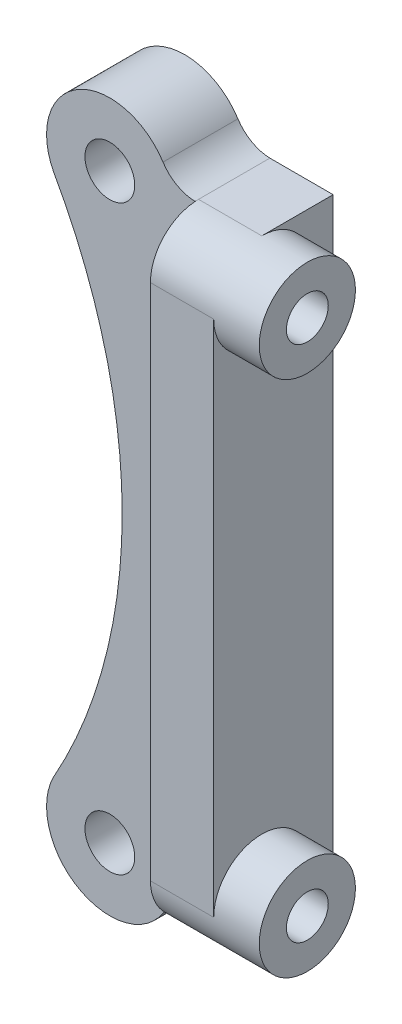
from build123d import *

# Parameters (mm, degrees)
EXTRUDE1_DEPTH     = 15.875
SKETCH2_R          = 12.065
EXTRUDE2_DEPTH     = 11.43
EXTRUDE4_DEPTH     = 18.796
SKETCH5_R          = 6.2484
CUT_EXTRUDE1_DEPTH = 19.796
SKETCH7_R          = 5.25018
CUT_EXTRUDE2_DEPTH = 25.4


with BuildPart() as part:
    # Sketch1 → Extrude1 (new body)
    with BuildSketch(Plane(origin=(0, 0, 0), x_dir=(0, 0, -1), z_dir=(1, 0, 0))):
        with BuildLine():
            Line((17.907, -77.0636), (17.907, 77.0636))
            Line((17.907, 77.0636), (0, 77.0636))
            ThreePointArc((0, 77.0636), (-8.531243315, 73.529843315), (-12.065, 64.9986))
            Line((-12.065, 64.9986), (-12.065, -64.9986))
            ThreePointArc((-12.065, -64.9986), (-8.531243315, -73.529843315), (0, -77.0636))
            Line((0, -77.0636), (17.907, -77.0636))
        make_face()
    extrude(amount=EXTRUDE1_DEPTH)

    # Sketch2 → Extrude2 (add)
    with BuildSketch(Plane(origin=(15.875, 0, 0), x_dir=(0, 0, -1), z_dir=(1, 0, 0))):
        with Locations(Location((0, 64.9986, 0), (0, 0, 180))):  # turned: the seam where the file's is
            Circle(SKETCH2_R)
    extrude2 = extrude(amount=EXTRUDE2_DEPTH)

    # Mirror of Extrude 2: Extrude2 across plane
    add(extrude2.mirror(Plane.ZX))

    # Sketch4 → Extrude4 (add)
    with BuildSketch(Plane(origin=(0, 0, -17.907), x_dir=(-1, 0, 0), z_dir=(0, 0, -1))):
        with BuildLine():
            ThreePointArc((8.015455062, 81.59619111), (4.56701856, 78.340842715), (0, 77.0636))
            Line((0, 77.0636), (0, -77.0636))
            ThreePointArc((0, -77.0636), (4.56701856, -78.340842715), (8.015455062, -81.59619111))
            ThreePointArc((8.015455062, -81.59619111), (29.290525196, -86.75258508), (35.488071258, -65.757170562))
            ThreePointArc((35.488071258, -65.757170562), (18.264230861, 0), (35.488071258, 65.757170562))
            ThreePointArc((35.488071258, 65.757170562), (29.290525196, 86.75258508), (8.015455062, 81.59619111))
        make_face()
    extrude(amount=-EXTRUDE4_DEPTH)

    # Sketch5 → Cut-Extrude1 (cut, through all)
    with BuildSketch(Plane.XY.offset(0.889)):
        with Locations((-21.3614, 72.9996)):
            Circle(SKETCH5_R)
    cut_extrude1 = extrude(amount=-CUT_EXTRUDE1_DEPTH, mode=Mode.SUBTRACT)

    # Sketch7 → Cut-Extrude2 (cut)
    with BuildSketch(Plane(origin=(27.305, 0, 0), x_dir=(0, 0, -1), z_dir=(1, 0, 0))):
        with Locations((0, 64.9986)):
            Circle(SKETCH7_R)
    cut_extrude2 = extrude(amount=-CUT_EXTRUDE2_DEPTH, mode=Mode.SUBTRACT)

    # Mirror1: Cut-Extrude1, Cut-Extrude2 across plane
    add(cut_extrude1.mirror(Plane.ZX), mode=Mode.SUBTRACT)
    add(cut_extrude2.mirror(Plane.ZX), mode=Mode.SUBTRACT)


solid = part.part
